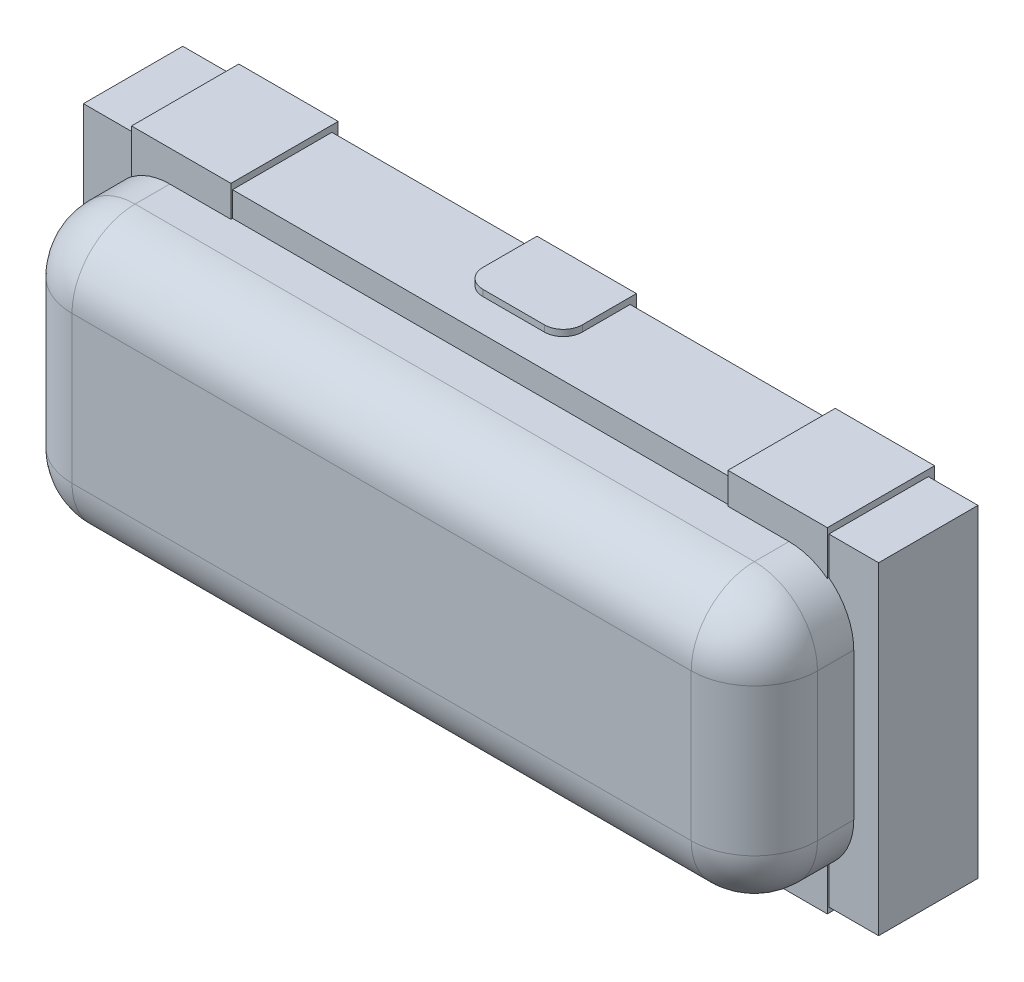
from build123d import *

# Parameters (mm, degrees)
SKETCH1_W                = 3.2
SKETCH1_H                = 1.3
BOSS_EXTRUDE1_DEPTH      = 0.4
SKETCH2_W                = 3
SKETCH2_H                = 1.1
BOSS_EXTRUDE2_DEPTH      = 0.4
FILLET1_R                = 0.254
SKETCH3_W                = 0.4
SKETCH3_H                = 1.3
BOSS_EXTRUDE3_DEPTH      = 0.0254
SKETCH4_W                = 0.4
SKETCH4_H                = 0.4318
BOSS_EXTRUDE4_DEPTH      = 0.0254
BOSS_EXTRUDE4_DEPTH_BACK = 1.3208


with BuildPart() as part:
    # Sketch1 → Boss-Extrude1 (new body)
    with BuildSketch(Plane.XY):
        with Locations((1.6, 0.65)):
            Rectangle(SKETCH1_W, SKETCH1_H)
    extrude(amount=BOSS_EXTRUDE1_DEPTH)

    # Sketch2 → Boss-Extrude2 (add)
    with BuildSketch(Plane.XY.offset(0.4)):
        with Locations((1.6, 0.65)):
            Rectangle(SKETCH2_W, SKETCH2_H)
    extrude(amount=BOSS_EXTRUDE2_DEPTH)

    # Fillet1
    fillet1_edges = [part.edges().sort_by_distance(p)[0] for p in [
        (0.1, 1.2, 0.6),
        (0.1, 0.1, 0.6),
        (3.1, 0.1, 0.6),
        (3.1, 1.2, 0.6),
        (0.1, 0.65, 0.8),
        (1.6, 0.1, 0.8),
        (3.1, 0.65, 0.8),
        (1.6, 1.2, 0.8),
    ]]
    fillet(fillet1_edges, radius=FILLET1_R)

    # Sketch3 → Boss-Extrude3 (add)
    with BuildSketch(Plane(origin=(0, 0, 0), x_dir=(-1, 0, 0), z_dir=(0, 0, -1))):
        with Locations((-0.4, 0.65)):
            Rectangle(SKETCH3_W, SKETCH3_H)
        with Locations((-2.8, 0.65)):
            Rectangle(SKETCH3_W, SKETCH3_H)
        with Locations((-1.6, 0.65)):
            Rectangle(SKETCH3_W, SKETCH3_H)
    extrude(amount=BOSS_EXTRUDE3_DEPTH)

    # Sketch4 → Boss-Extrude4 (add, two sides)
    with BuildSketch(Plane(origin=(0, 1.3, 0), x_dir=(1, 0, 0), z_dir=(0, 1, 0))) as boss_extrude4_sk:
        with BuildLine():
            Line((1.4, 0.0254), (1.4, -0.192503839))
            ThreePointArc((1.4, -0.192503839), (1.422318463, -0.246385375), (1.4762, -0.268703839))
            Line((1.4762, -0.268703839), (1.7238, -0.268703839))
            ThreePointArc((1.7238, -0.268703839), (1.777681537, -0.246385375), (1.8, -0.192503839))
            Line((1.8, -0.192503839), (1.8, 0.0254))
            Line((1.8, 0.0254), (1.4, 0.0254))
        make_face()
        with Locations((0.4, -0.1905)):
            Rectangle(SKETCH4_W, SKETCH4_H)
        with Locations((2.8, -0.1905)):
            Rectangle(SKETCH4_W, SKETCH4_H)
    extrude(amount=BOSS_EXTRUDE4_DEPTH)
    extrude(boss_extrude4_sk.sketch, amount=-BOSS_EXTRUDE4_DEPTH_BACK)


solid = part.part
